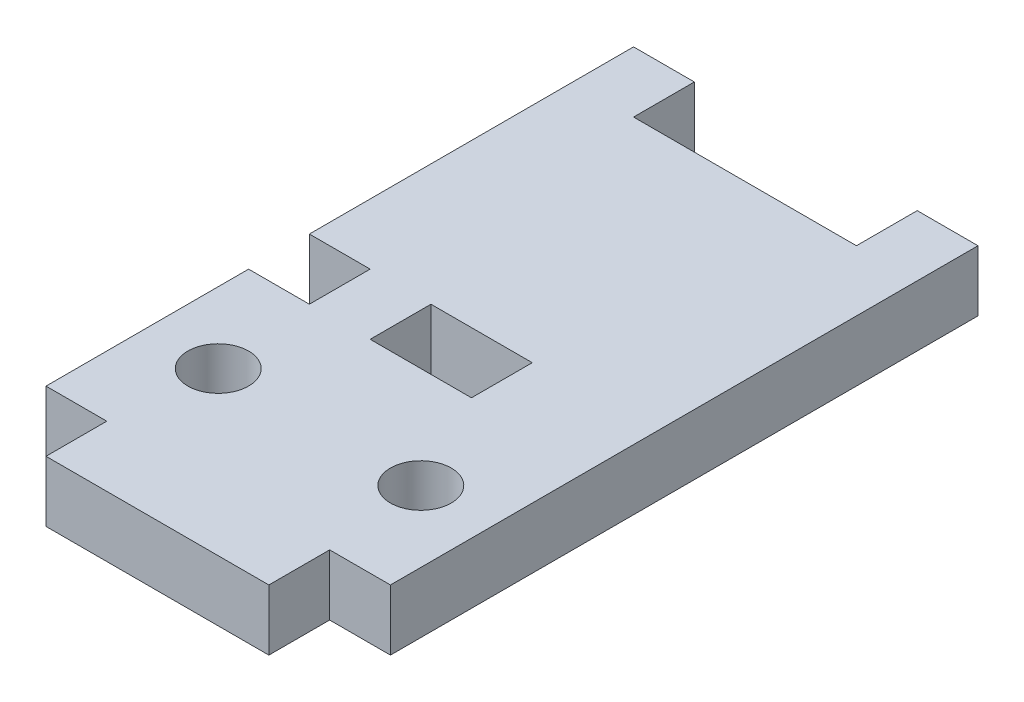
from build123d import *

# Parameters (mm, degrees)
SKETCH1_W               = 17
SKETCH1_H               = 29
BOSS_EXTRUDE1_DEPTH     = 1.5
SKETCH2_W               = 11
SKETCH2_H               = 3
BOSS_EXTRUDE2_DEPTH     = 1.5
SKETCH3_W               = 5
SKETCH3_H               = 3
SKETCH3_W_2             = 11
SKETCH3_W_3             = 3
CUT_EXTRUDE1_DEPTH      = 2.5
CUT_EXTRUDE1_DEPTH_BACK = 2.5
SKETCH5_R               = 1.5
CUT_EXTRUDE3_DEPTH      = 2.5
CUT_EXTRUDE3_DEPTH_BACK = 2.5


with BuildPart() as part:
    # Sketch1 → Boss-Extrude1 (new body, symmetric)
    with BuildSketch(Plane(origin=(0, 0, 0), x_dir=(1, 0, 0), z_dir=(0, 1, 0))):
        Rectangle(SKETCH1_W, SKETCH1_H)
    extrude(amount=BOSS_EXTRUDE1_DEPTH, both=True)

    # Sketch2 → Boss-Extrude2 (add, symmetric)
    with BuildSketch(Plane(origin=(0, 0, 0), x_dir=(1, 0, 0), z_dir=(0, 1, 0))):
        with Locations((0, -16)):
            Rectangle(SKETCH2_W, SKETCH2_H)
    extrude(amount=BOSS_EXTRUDE2_DEPTH, both=True)

    # Sketch3 → Cut-Extrude1 (cut, two sides)
    with BuildSketch(Plane(origin=(0, 0, 0), x_dir=(1, 0, 0), z_dir=(0, 1, 0))) as cut_extrude1_sk:
        with Locations((0, -3)):
            Rectangle(SKETCH3_W, SKETCH3_H)
        with Locations((0, 13)):
            Rectangle(SKETCH3_W_2, SKETCH3_H)
        with Locations((-7, -3)):
            Rectangle(SKETCH3_W_3, SKETCH3_H)
    extrude(amount=CUT_EXTRUDE1_DEPTH, mode=Mode.SUBTRACT)
    extrude(cut_extrude1_sk.sketch, amount=-CUT_EXTRUDE1_DEPTH_BACK, mode=Mode.SUBTRACT)

    # Sketch5 → Cut-Extrude3 (cut, two sides)
    with BuildSketch(Plane(origin=(0, 0, 0), x_dir=(1, 0, 0), z_dir=(0, 1, 0))) as cut_extrude3_sk:
        with Locations((-5, -9.5)):
            Circle(SKETCH5_R)
        with Locations((5, -9.5)):
            Circle(SKETCH5_R)
    extrude(amount=CUT_EXTRUDE3_DEPTH, mode=Mode.SUBTRACT)
    extrude(cut_extrude3_sk.sketch, amount=-CUT_EXTRUDE3_DEPTH_BACK, mode=Mode.SUBTRACT)


solid = part.part
